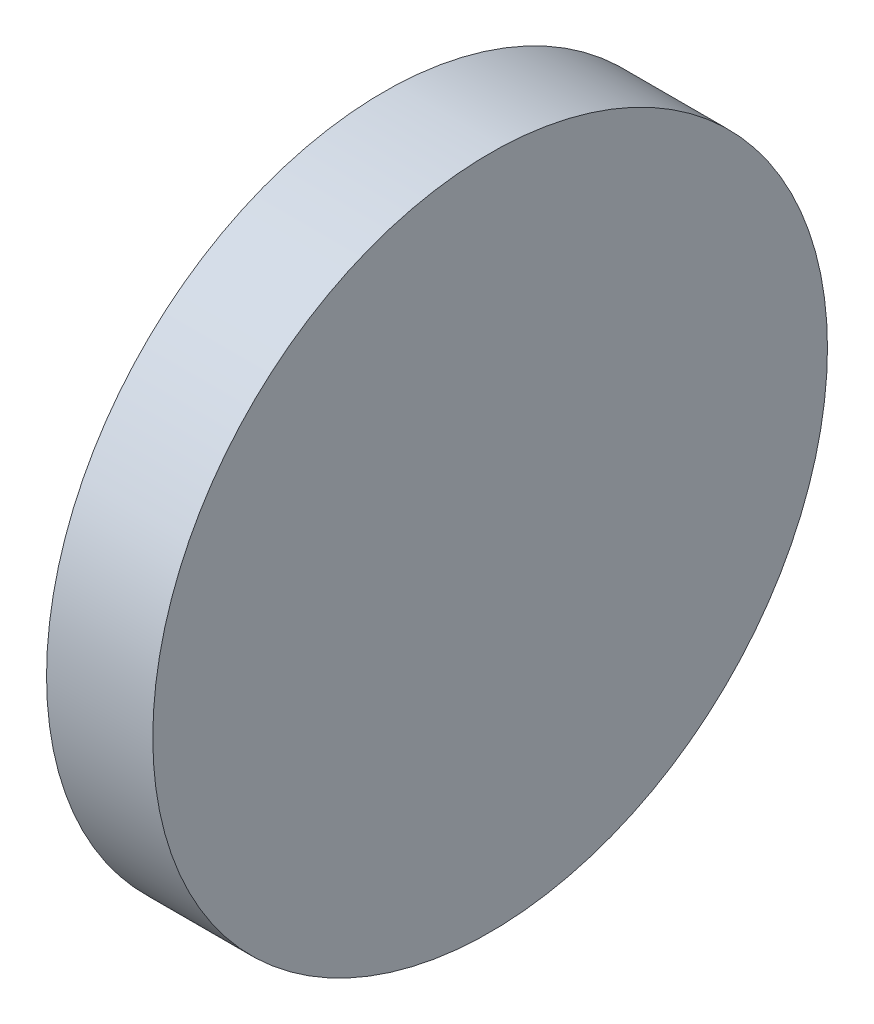
from build123d import *

# Parameters (mm, degrees)
SKETCH_1_W = 2
SKETCH_1_H = 6.35


with BuildPart() as part:
    # 草图1 → 旋转2 (revolve)
    with BuildSketch(Plane.XY, mode=Mode.PRIVATE) as revolve_2_sk:
        with Locations((1, 3.175)):
            Rectangle(SKETCH_1_W, SKETCH_1_H)
    revolve(revolve_2_sk.sketch.rotate(Axis((0, 0, 0), (1, 0, 0)), 90), axis=Axis((0, 0, 0), (1, 0, 0)))  # turned: the seam where the file's is


solid = part.part
